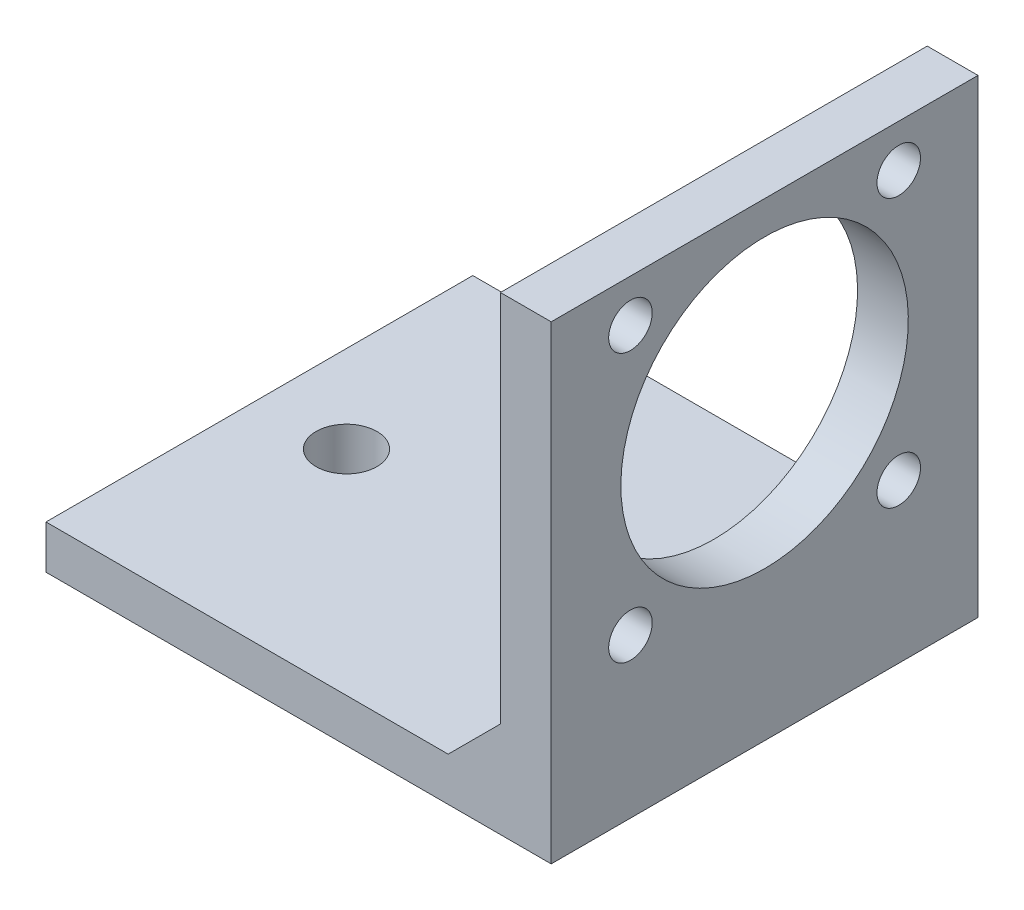
from build123d import *

# Parameters (mm, degrees)
SKETCH1_W               = 2.914347554
SKETCH1_H               = 25
SKETCH1_W_2             = 29
SKETCH1_H_2             = 2.5
BOSS_EXTRUDE1_DEPTH     = 24.5
SKETCH2_R               = 1.25
CUT_EXTRUDE1_DEPTH      = 30
SKETCH3_R               = 1.75
CUT_EXTRUDE2_DEPTH      = 26
CUT_EXTRUDE2_DEPTH_BACK = 3.5
SKETCH4_R               = 8.25
CUT_EXTRUDE3_DEPTH      = 27.085652446
CUT_EXTRUDE3_DEPTH_BACK = 3.914347554
SKETCH5_W               = 2.914347554
SKETCH5_H               = 0.55
CUT_EXTRUDE4_DEPTH      = 1
CUT_EXTRUDE4_DEPTH_BACK = 25.5
CHAMFER1_SIZE           = 3


with BuildPart() as part:
    # Sketch1 → Boss-Extrude1 (new body)
    with BuildSketch(Plane.XY):
        with Locations((27.542826223, 15)):
            Rectangle(SKETCH1_W, SKETCH1_H)
        with Locations((14.5, 1.25)):
            Rectangle(SKETCH1_W_2, SKETCH1_H_2)
    extrude(amount=BOSS_EXTRUDE1_DEPTH)

    # Sketch2 → Cut-Extrude1 (cut, through all)
    with BuildSketch(Plane(origin=(29, 0, 0), x_dir=(0, 0, -1), z_dir=(1, 0, 0))):
        with Locations((-19.95, 24.5)):
            Circle(SKETCH2_R)
        with Locations((-4.55, 24.5)):
            Circle(SKETCH2_R)
        with Locations((-4.55, 9.1)):
            Circle(SKETCH2_R)
        with Locations((-19.95, 9.1)):
            Circle(SKETCH2_R)
    extrude(amount=-CUT_EXTRUDE1_DEPTH, mode=Mode.SUBTRACT)

    # Sketch3 → Cut-Extrude2 (cut, two sides)
    with BuildSketch(Plane(origin=(0, 2.5, 0), x_dir=(1, 0, 0), z_dir=(0, 1, 0))) as cut_extrude2_sk:
        with Locations((5, -12.25)):
            Circle(SKETCH3_R)
        with Locations((20, -12.25)):
            Circle(SKETCH3_R)
    extrude(amount=CUT_EXTRUDE2_DEPTH, mode=Mode.SUBTRACT)
    extrude(cut_extrude2_sk.sketch, amount=-CUT_EXTRUDE2_DEPTH_BACK, mode=Mode.SUBTRACT)

    # Sketch4 → Cut-Extrude3 (cut, two sides)
    with BuildSketch(Plane.ZY.offset(-26.085652446)) as cut_extrude3_sk:
        with Locations((12.25, 16.8)):
            Circle(SKETCH4_R)
    extrude(amount=CUT_EXTRUDE3_DEPTH, mode=Mode.SUBTRACT)
    extrude(cut_extrude3_sk.sketch, amount=-CUT_EXTRUDE3_DEPTH_BACK, mode=Mode.SUBTRACT)

    # Sketch5 → Cut-Extrude4 (cut, two sides)
    with BuildSketch(Plane.XY.offset(24.5)) as cut_extrude4_sk:
        with Locations((27.542826223, 27.225)):
            Rectangle(SKETCH5_W, SKETCH5_H)
    extrude(amount=CUT_EXTRUDE4_DEPTH, mode=Mode.SUBTRACT)
    extrude(cut_extrude4_sk.sketch, amount=-CUT_EXTRUDE4_DEPTH_BACK, mode=Mode.SUBTRACT)

    # Chamfer1
    chamfer1_edges = [part.edges().sort_by_distance(p)[0] for p in [
        (26.085652446, 2.5, 12.25),
    ]]
    chamfer(chamfer1_edges, length=CHAMFER1_SIZE)


solid = part.part
